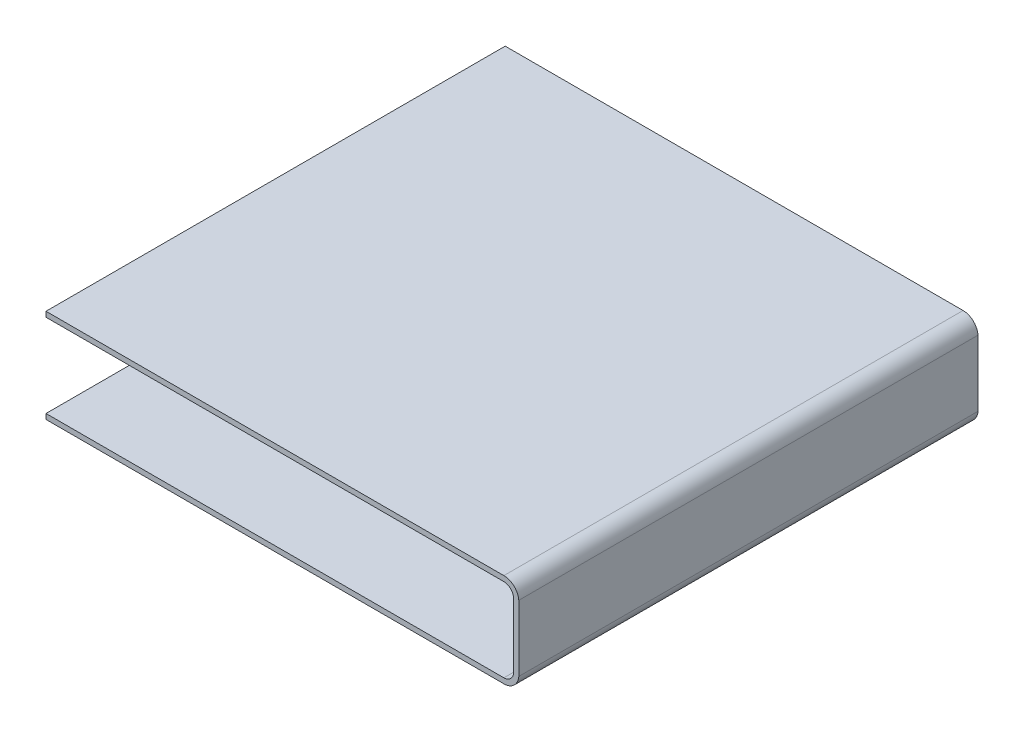
from build123d import *

# Parameters (mm, degrees)
EXTRUDE_THIN3_DEPTH = 9680


with BuildPart() as part:
    # Sketch1 → Extrude-Thin3 (new body)
    with BuildSketch(Plane.XY):
        with BuildLine():
            Line((-1262.295629579, 1976), (8389.704370421, 1976))
            ThreePointArc((8389.704370421, 1976), (8604.800493219, 1891.347594916), (8704.507000955, 1682.802673989))
            Line((8704.507000955, 1682.802673989), (8704.507000955, 293.197326011))
            ThreePointArc((8704.507000955, 293.197326011), (8604.800493219, 84.652405084), (8389.704370421, 0))
            Line((8389.704370421, 0), (-1262.295629579, 0))
            Line((-1262.295629579, 0), (-1262.295629579, 110))
            Line((-1262.295629579, 110), (8389.704370421, 110))
            ThreePointArc((8389.704370421, 110), (8528.547244904, 163.962696181), (8594.507000955, 297.524019009))
            Line((8594.507000955, 297.524019009), (8594.507000955, 1678.475980991))
            ThreePointArc((8594.507000955, 1678.475980991), (8528.547244904, 1812.037303819), (8389.704370421, 1866))
            Line((8389.704370421, 1866), (-1262.295629579, 1866))
            Line((-1262.295629579, 1866), (-1262.295629579, 1976))
        make_face()
    extrude(amount=EXTRUDE_THIN3_DEPTH)


solid = part.part
